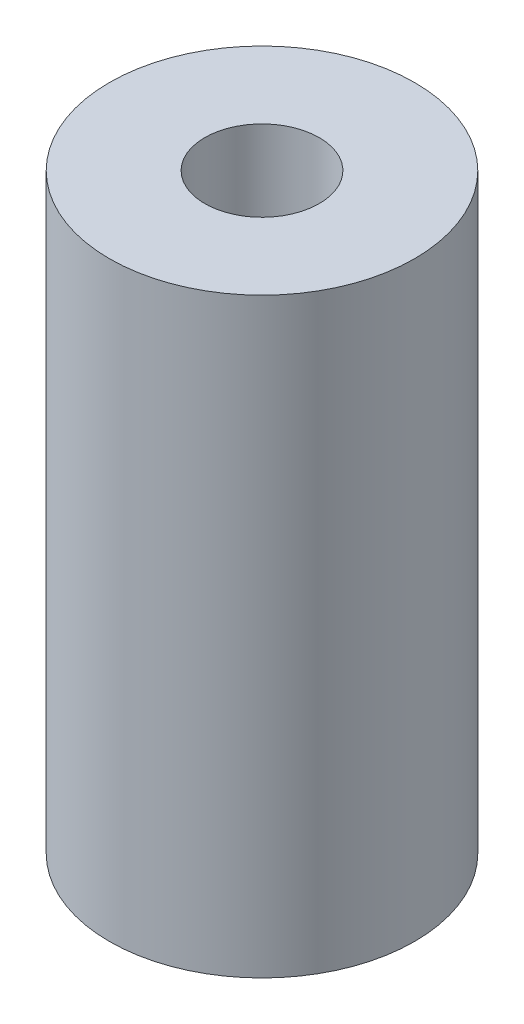
from build123d import *

# Parameters (mm, degrees)
SKETCH_1_W = 2.5
SKETCH_1_H = 15.5


with BuildPart() as part:
    # Эскиз1 → Повернуть1 (revolve)
    with BuildSketch(Plane.XY):
        with Locations((2.75, 7.786590587)):
            Rectangle(SKETCH_1_W, SKETCH_1_H)
    revolve(axis=Axis((0, 0, 0), (0, 1, 0)))


solid = part.part
